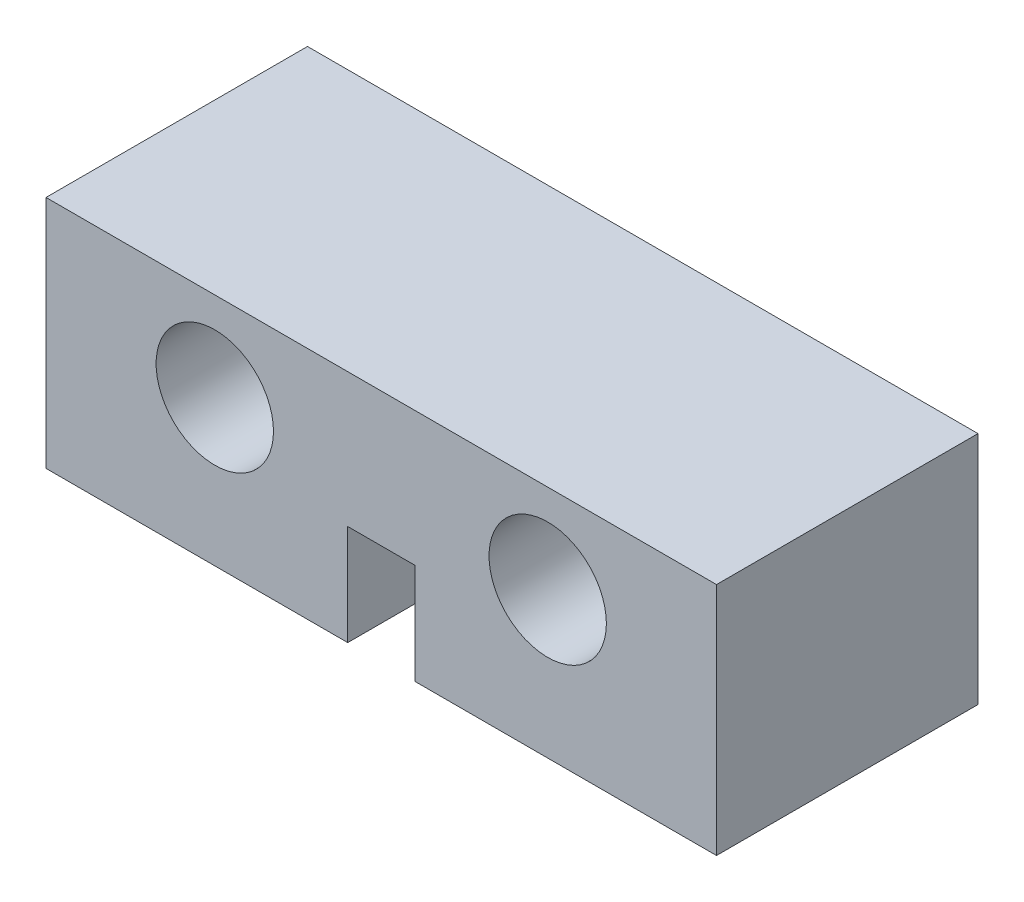
from build123d import *

# Parameters (mm, degrees)
SKETCH_1_W          = 20
SKETCH_1_H          = 7
EXTRUDE_1_DEPTH     = 7.8
SKETCH_2_R          = 1.75
CUT_EXTRUDE_1_DEPTH = 7.8
SKETCH_3_W          = 2
SKETCH_3_H          = 3
CUT_EXTRUDE_2_DEPTH = 7.8


with BuildPart() as part:
    # 草图1 → 凸台-拉伸1 (new body)
    with BuildSketch(Plane.XY):
        Rectangle(SKETCH_1_W, SKETCH_1_H)
    extrude(amount=EXTRUDE_1_DEPTH)

    # 草图2 → 切除-拉伸1 (cut)
    with BuildSketch(Plane.XY.offset(7.8)):
        with Locations((-4.965, 0.85)):
            Circle(SKETCH_2_R)
        with Locations((4.965, 0.85)):
            Circle(SKETCH_2_R)
    extrude(amount=-CUT_EXTRUDE_1_DEPTH, mode=Mode.SUBTRACT)

    # 草图3 → 切除-拉伸2 (cut)
    with BuildSketch(Plane.XY.offset(7.8)):
        with Locations((0, -2)):
            Rectangle(SKETCH_3_W, SKETCH_3_H)
    extrude(amount=-CUT_EXTRUDE_2_DEPTH, mode=Mode.SUBTRACT)


solid = part.part
